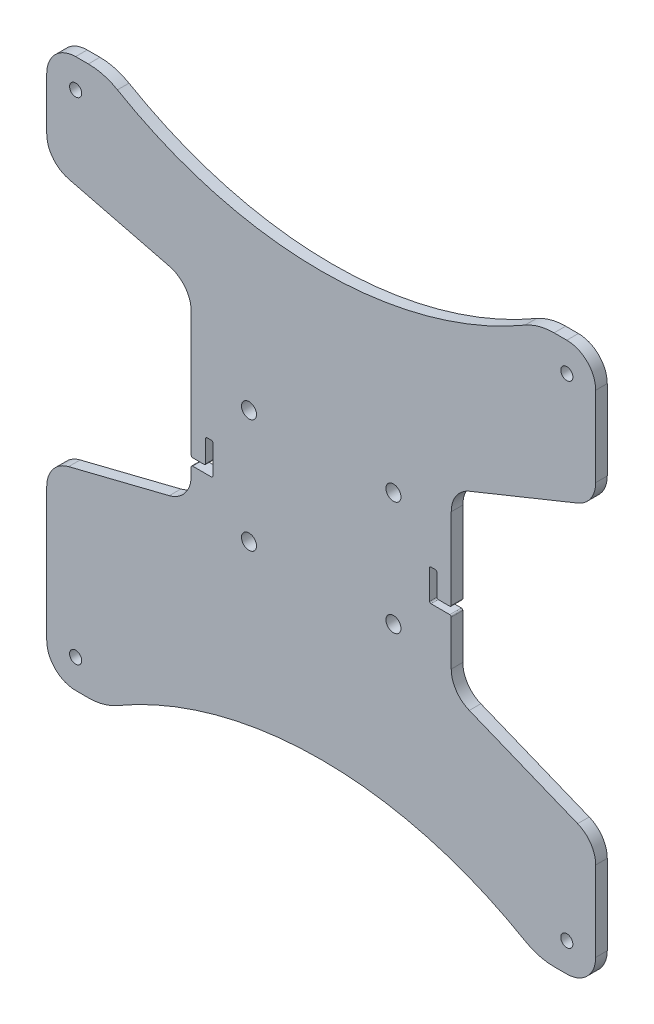
from build123d import *

# Parameters (mm, degrees)
SKETCH1_R           = 2.1
SKETCH1_R_2         = 2.6
BOSS_EXTRUDE1_DEPTH = 4


with BuildPart() as part:
    # Sketch1 → Boss-Extrude1 (new body)
    with BuildSketch(Plane(origin=(0, 0, 0), x_dir=(-1, 0, 0), z_dir=(0, 0, -1))):
        with BuildLine():
            Line((87.42535625, -29.106339063), (52.57464375, -20.393660937))
            ThreePointArc((52.57464375, -20.393660937), (47.11794562, -16.84635803), (45, -10.692235936))
            Line((45, -10.692235936), (45, -8))
            ThreePointArc((45, -8), (44.853553391, -7.646446609), (44.5, -7.5))
            Line((44.5, -7.5), (38, -7.5))
            ThreePointArc((38, -7.5), (37.646446609, -7.353553391), (37.5, -7))
            Line((37.5, -7), (37.5, 3))
            ThreePointArc((37.5, 3), (37.646446609, 3.353553391), (38, 3.5))
            Line((38, 3.5), (39.5, 3.5))
            ThreePointArc((39.5, 3.5), (39.853553391, 3.353553391), (40, 3))
            Line((40, 3), (40, -4.5))
            ThreePointArc((40, -4.5), (40.146446609, -4.853553391), (40.5, -5))
            Line((40.5, -5), (44.5, -5))
            ThreePointArc((44.5, -5), (44.853553391, -4.853553391), (45, -4.5))
            Line((45, -4.5), (45, 38.692235936))
            ThreePointArc((45, 38.692235936), (47.11794562, 44.84635803), (52.57464375, 48.393660937))
            Line((52.57464375, 48.393660937), (87.42535625, 57.106339063))
            ThreePointArc((87.42535625, 57.106339063), (92.88205438, 60.65364197), (95, 66.807764064))
            Line((95, 66.807764064), (95, 85))
            ThreePointArc((95, 85), (92.071067812, 92.071067812), (85, 95))
            Line((85, 95), (80.600023778, 95))
            ThreePointArc((80.600023778, 95), (75.38177505, 94.307249421), (70.525020806, 92.276988022))
            ThreePointArc((70.525020806, 92.276988022), (0, 73.215904175), (-70.525020806, 92.276988022))
            ThreePointArc((-70.525020806, 92.276988022), (-75.38177505, 94.307249421), (-80.600023778, 95))
            Line((-80.600023778, 95), (-85, 95))
            ThreePointArc((-85, 95), (-92.071067812, 92.071067812), (-95, 85))
            Line((-95, 85), (-95, 57.30993956))
            ThreePointArc((-95, 57.30993956), (-93.292887614, 51.721736358), (-88.754396995, 48.041471336))
            Line((-88.754396995, 48.041471336), (-51.245603005, 32.847708996))
            ThreePointArc((-51.245603005, 32.847708996), (-46.707112386, 29.167443975), (-45, 23.579240773))
            Line((-45, 23.579240773), (-45, -4.5))
            ThreePointArc((-45, -4.5), (-44.853553391, -4.853553391), (-44.5, -5))
            Line((-44.5, -5), (-40.5, -5))
            ThreePointArc((-40.5, -5), (-40.146446609, -4.853553391), (-40, -4.5))
            Line((-40, -4.5), (-40, 3))
            ThreePointArc((-40, 3), (-39.853553391, 3.353553391), (-39.5, 3.5))
            Line((-39.5, 3.5), (-38, 3.5))
            ThreePointArc((-38, 3.5), (-37.646446609, 3.353553391), (-37.5, 3))
            Line((-37.5, 3), (-37.5, -7))
            ThreePointArc((-37.5, -7), (-37.646446609, -7.353553391), (-38, -7.5))
            Line((-38, -7.5), (-44.5, -7.5))
            ThreePointArc((-44.5, -7.5), (-44.853553391, -7.646446609), (-45, -8))
            Line((-45, -8), (-45, -23.579240773))
            ThreePointArc((-45, -23.579240773), (-46.707112386, -29.167443975), (-51.245603005, -32.847708996))
            Line((-51.245603005, -32.847708996), (-88.754396995, -48.041471336))
            ThreePointArc((-88.754396995, -48.041471336), (-93.292887614, -51.721736358), (-95, -57.30993956))
            Line((-95, -57.30993956), (-95, -85))
            ThreePointArc((-95, -85), (-92.071067812, -92.071067812), (-85, -95))
            Line((-85, -95), (-80.600023778, -95))
            ThreePointArc((-80.600023778, -95), (-75.38177505, -94.307249421), (-70.525020806, -92.276988022))
            ThreePointArc((-70.525020806, -92.276988022), (0, -73.215904175), (70.525020806, -92.276988022))
            ThreePointArc((70.525020806, -92.276988022), (75.38177505, -94.307249421), (80.600023778, -95))
            Line((80.600023778, -95), (85, -95))
            ThreePointArc((85, -95), (92.071067812, -92.071067812), (95, -85))
            Line((95, -85), (95, -38.807764064))
            ThreePointArc((95, -38.807764064), (92.88205438, -32.65364197), (87.42535625, -29.106339063))
        make_face()
        with Locations((-85, -85)):
            Circle(SKETCH1_R, mode=Mode.SUBTRACT)
        with Locations((-85, 85)):
            Circle(SKETCH1_R, mode=Mode.SUBTRACT)
        with Locations((85, 85)):
            Circle(SKETCH1_R, mode=Mode.SUBTRACT)
        with Locations((85, -85)):
            Circle(SKETCH1_R, mode=Mode.SUBTRACT)
        with Locations((25, 19.006339063)):
            Circle(SKETCH1_R_2, mode=Mode.SUBTRACT)
        with Locations((25, -20.393660937)):
            Circle(SKETCH1_R_2, mode=Mode.SUBTRACT)
        with Locations((-25, -20.1)):
            Circle(SKETCH1_R_2, mode=Mode.SUBTRACT)
        with Locations((-25, 19.3)):
            Circle(SKETCH1_R_2, mode=Mode.SUBTRACT)
    extrude(amount=-BOSS_EXTRUDE1_DEPTH)


solid = part.part
